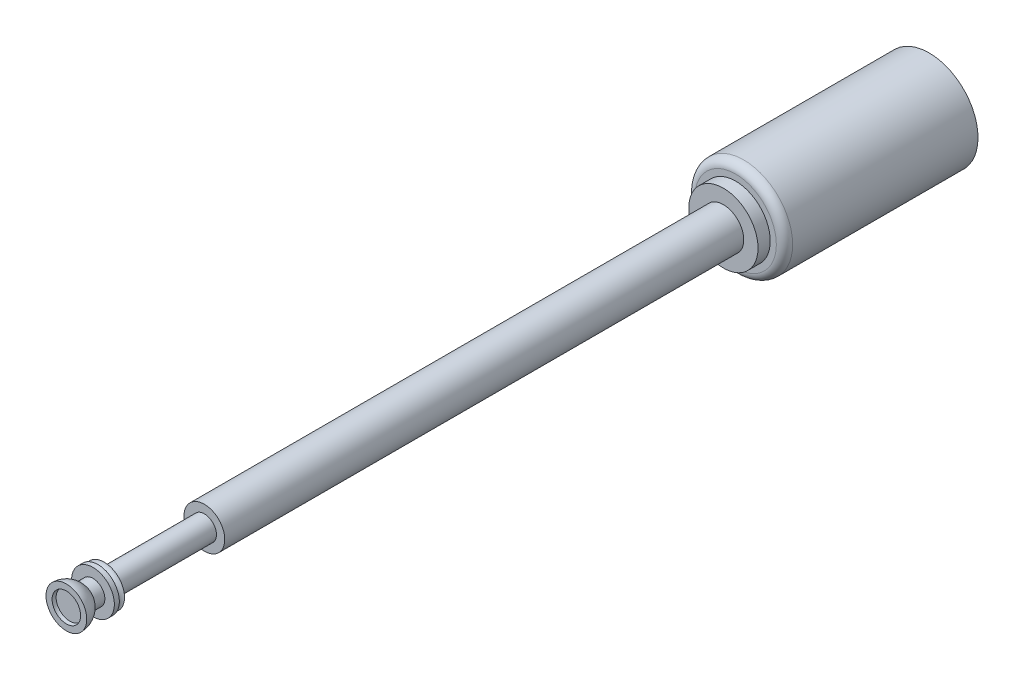
from build123d import *

# Parameters (mm, degrees)
SKETCH2_R           = 0.5
BOSS_EXTRUDE1_DEPTH = 15.5
SKETCH2_6_R         = 1.2
SKETCH2_6_R_2       = 0.5
BOSS_EXTRUDE3_DEPTH = 4.75
BOSS_EXTRUDE4_START = 4.75
SKETCH3_R           = 0.5
BOSS_EXTRUDE4_DEPTH = 4.75
FILLET1_R           = 0.2
SKETCH4_R           = 0.85
BOSS_EXTRUDE5_DEPTH = 0.3
SKETCH6_W           = 0.466741821
SKETCH6_H           = 0.031322261
SKETCH7_W           = 1.509947497
SKETCH7_H           = 2.46


with BuildPart() as part:
    # Sketch2 → Boss-Extrude1 (new body)
    with BuildSketch(Plane.XY):
        Circle(SKETCH2_R)
    extrude(amount=BOSS_EXTRUDE1_DEPTH)


with BuildPart() as body_2:
    # Sketch2_6 → Boss-Extrude3 (new body)
    with BuildSketch(Plane.XY):
        Circle(SKETCH2_6_R)
        Circle(SKETCH2_6_R_2, mode=Mode.SUBTRACT)
    extrude(amount=-BOSS_EXTRUDE3_DEPTH)


with BuildPart() as boss_extrude4_tool:
    # Sketch3 → Boss-Extrude4 (new body)
    with BuildSketch(Plane(origin=(0, 0, 0), x_dir=(-1, 0, 0), z_dir=(0, 0, -1)).offset(BOSS_EXTRUDE4_START)):
        Circle(SKETCH3_R)
    extrude(amount=-BOSS_EXTRUDE4_DEPTH)


with BuildPart() as part_1:
    add(part.part)


with BuildPart() as part_2:
    # Boss-Extrude4: joined with boss_extrude4_tool
    add(part_1.part.fuse(boss_extrude4_tool.part, body_2.part, tol=0.00001))

    # Fillet1
    fillet1_edges = [part_2.edges().sort_by_distance(p)[0] for p in [
        (-1.2, 0, 0),
    ]]
    fillet(fillet1_edges, radius=FILLET1_R)

    # Sketch4 → Boss-Extrude5 (add)
    with BuildSketch(Plane.XY):
        Circle(SKETCH4_R)
    extrude(amount=BOSS_EXTRUDE5_DEPTH)

    # Sketch5 → Revolve1 (revolve)
    with BuildSketch(Plane(origin=(0, 0, 0), x_dir=(1, 0, 0), z_dir=(0, 1, 0))):
        with BuildLine():
            Line((0.5, -15.5), (0, -15.5))
            Line((0, -15.5), (0, -16.0775))
            ThreePointArc((0, -16.0775), (0.247487373, -16.180012627), (0.35, -16.4275))
            Line((0.35, -16.4275), (0.5, -16.4275))
            ThreePointArc((0.5, -16.4275), (0.44489867, -16.199322057), (0.291739306, -16.021435747))
            Line((0.291739306, -16.021435747), (0.291739306, -15.774240314))
            Line((0.291739306, -15.774240314), (0.524883028, -15.774240314))
            Line((0.524883028, -15.774240314), (0.524883028, -15.652417135))
            Line((0.524883028, -15.652417135), (0.376771599, -15.652417135))
            ThreePointArc((0.376771599, -15.652417135), (0.411432347, -15.554416852), (0.5, -15.5))
        make_face()
    revolve(axis=Axis((0, 0, 15.5), (0, 0, 1)))

    # Sketch6 → Revolve2 (revolve)
    with BuildSketch(Plane(origin=(0, 0, 0), x_dir=(1, 0, 0), z_dir=(0, 1, 0))):
        with Locations((-0.233370911, -16.32433887)):
            Rectangle(SKETCH6_W, SKETCH6_H)
    revolve(axis=Axis((0, 0, 16.4275), (0, 0, -1)))

    # Sketch7 → Cut-Revolve1 (revolve, cut)
    with BuildSketch(Plane(origin=(0, 0, 0), x_dir=(1, 0, 0), z_dir=(0, 1, 0))):
        with Locations((-1.051173749, -14.27)):
            Rectangle(SKETCH7_W, SKETCH7_H)
    revolve(axis=Axis((0, 0, 15.5), (0, 0, 1)), mode=Mode.SUBTRACT)


solid = part_2.part
